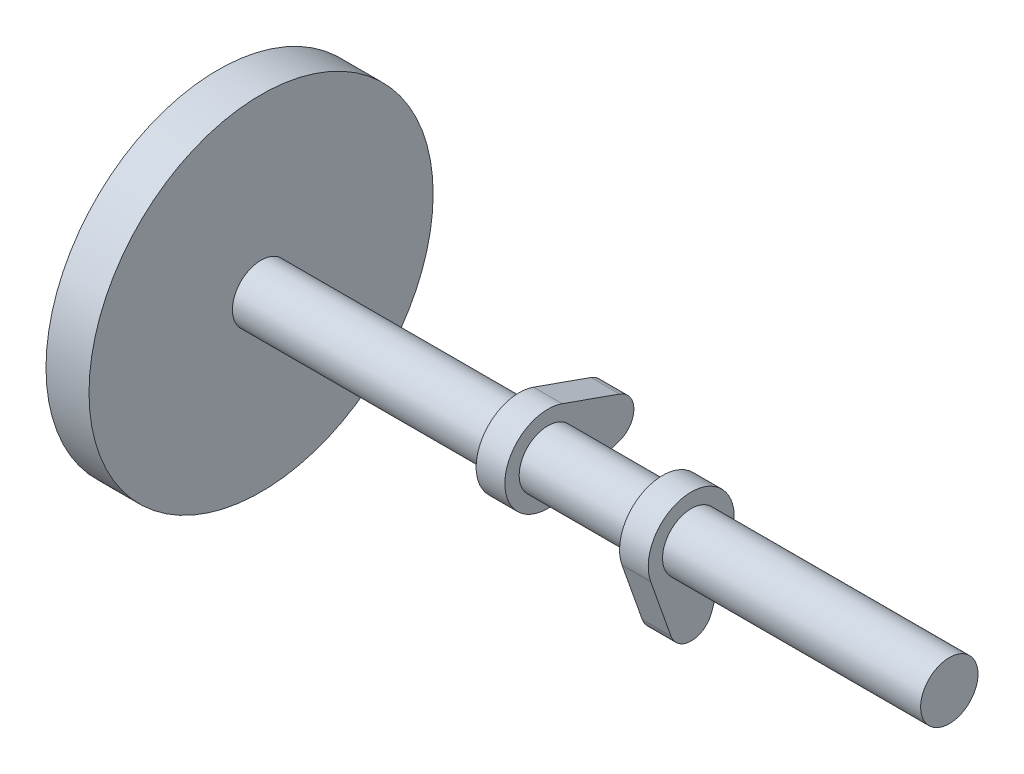
from build123d import *

# Parameters (mm, degrees)
SKETCH1_R             = 10
BOSS_EXTRUDE1_DEPTH   = 120
SKETCH3_R             = 10
BOSS_EXTRUDE2_DEPTH   = 5
BODY_MOVE_COPY1_ANGLE = 90
SKETCH5_R             = 60
BOSS_EXTRUDE3_DEPTH   = 15


with BuildPart() as part:
    # Sketch1 → Boss-Extrude1 (new body, symmetric)
    with BuildSketch(Plane(origin=(0, 0, 0), x_dir=(0, 0, -1), z_dir=(1, 0, 0))):
        Circle(SKETCH1_R)
    extrude(amount=BOSS_EXTRUDE1_DEPTH, both=True)


with BuildPart() as body_2:
    # Sketch3 → Boss-Extrude2 (new body, symmetric)
    with BuildSketch(Plane(origin=(25, 0, 0), x_dir=(0, 0, -1), z_dir=(1, 0, 0))):
        with BuildLine():
            Line((14.142135624, -5), (7.071067812, -25))
            ThreePointArc((7.071067812, -25), (0, -30), (-7.071067812, -25))
            Line((-7.071067812, -25), (-14.142135624, -5))
            ThreePointArc((-14.142135624, -5), (0, 15), (14.142135624, -5))
        make_face()
        Circle(SKETCH3_R, mode=Mode.SUBTRACT)
    extrude(amount=BOSS_EXTRUDE2_DEPTH, both=True)


with BuildPart() as body_3:
    # Mirror1: mirrored copy
    add(body_2.part.mirror(Plane(origin=(0, 0, 0), x_dir=(0, 0, 1), z_dir=(1, 0, 0))))


with BuildPart() as body_3_1:
    # Body-Move/Copy1: moved
    add(body_3.part.rotate(Axis((0, 0, 0), (1, 0, 0)), BODY_MOVE_COPY1_ANGLE))


with BuildPart() as part_1:
    add(part.part)

    # Combine1: union body 2, body 3
    add(body_2.part)
    add(body_3_1.part)


with BuildPart() as body_2_2:
    # Sketch5 → Boss-Extrude3 (new body)
    with BuildSketch(Plane.ZY.offset(120)):
        Circle(SKETCH5_R)
    extrude(amount=BOSS_EXTRUDE3_DEPTH)


solid = Compound([part_1.part, body_2_2.part])
